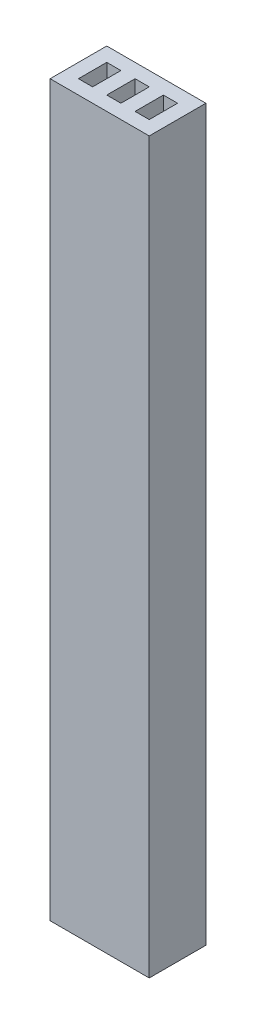
from build123d import *

# Parameters (mm, degrees)
SKETCH1_W           = 7
SKETCH1_H           = 4
SKETCH1_W_2         = 1
SKETCH1_H_2         = 2
BOSS_EXTRUDE1_DEPTH = 51.5


with BuildPart() as part:
    # Sketch1 → Boss-Extrude1 (new body)
    with BuildSketch(Plane(origin=(0, 0, 0), x_dir=(1, 0, 0), z_dir=(0, 1, 0))):
        with Locations((2.5, 1)):
            Rectangle(SKETCH1_W, SKETCH1_H)
        with Locations((0.5, 1)):
            Rectangle(SKETCH1_W_2, SKETCH1_H_2, mode=Mode.SUBTRACT)
        with Locations((2.5, 1)):
            Rectangle(SKETCH1_W_2, SKETCH1_H_2, mode=Mode.SUBTRACT)
        with Locations((4.5, 1)):
            Rectangle(SKETCH1_W_2, SKETCH1_H_2, mode=Mode.SUBTRACT)
    extrude(amount=BOSS_EXTRUDE1_DEPTH)


solid = part.part
